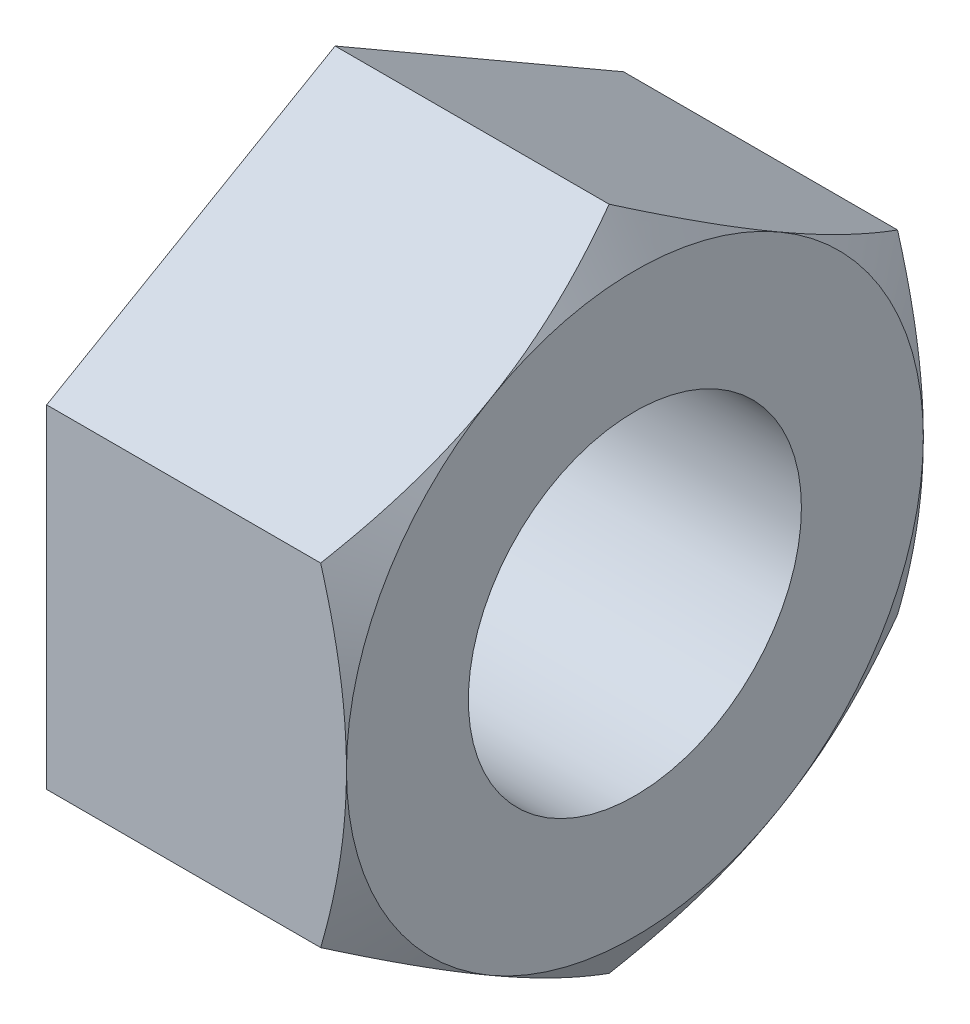
from build123d import *

# Parameters (mm, degrees)
BOSS_EXTRUDE1_DEPTH = 25.2
SKETCH2_R           = 14
CUT_EXTRUDE1_DEPTH  = 25.2
SKETCH3_OUTSIDE_W   = 153.444
SKETCH3_OUTSIDE_H   = 160.946
SKETCH3_OUTSIDE_R   = 24.248711306
CUT_EXTRUDE2_DEPTH  = 25.2
CUT_EXTRUDE2_TAPER  = 60


with BuildPart() as part:
    # Sketch1 → Boss-Extrude1 (new body)
    with BuildSketch(Plane(origin=(0, 0, 0), x_dir=(0, 0, -1), z_dir=(1, 0, 0))):
        Polygon((0, 28), (-24.248711306, 14), (-24.248711306, -14), (0, -28), (24.248711306, -14), (24.248711306, 14), align=None)
    extrude(amount=-BOSS_EXTRUDE1_DEPTH)

    # Sketch2 → Cut-Extrude1 (cut)
    with BuildSketch(Plane(origin=(0, 0, 0), x_dir=(0, 0, -1), z_dir=(1, 0, 0))):
        Circle(SKETCH2_R)
    extrude(amount=-CUT_EXTRUDE1_DEPTH, mode=Mode.SUBTRACT)

    # Sketch3 outside → Cut-Extrude2 (cut)
    with BuildSketch(Plane(origin=(0, 0, 0), x_dir=(0, 0, -1), z_dir=(1, 0, 0))):
        Rectangle(SKETCH3_OUTSIDE_W, SKETCH3_OUTSIDE_H)
        Circle(SKETCH3_OUTSIDE_R, mode=Mode.SUBTRACT)
    extrude(amount=-CUT_EXTRUDE2_DEPTH, taper=CUT_EXTRUDE2_TAPER, mode=Mode.SUBTRACT)


solid = part.part
